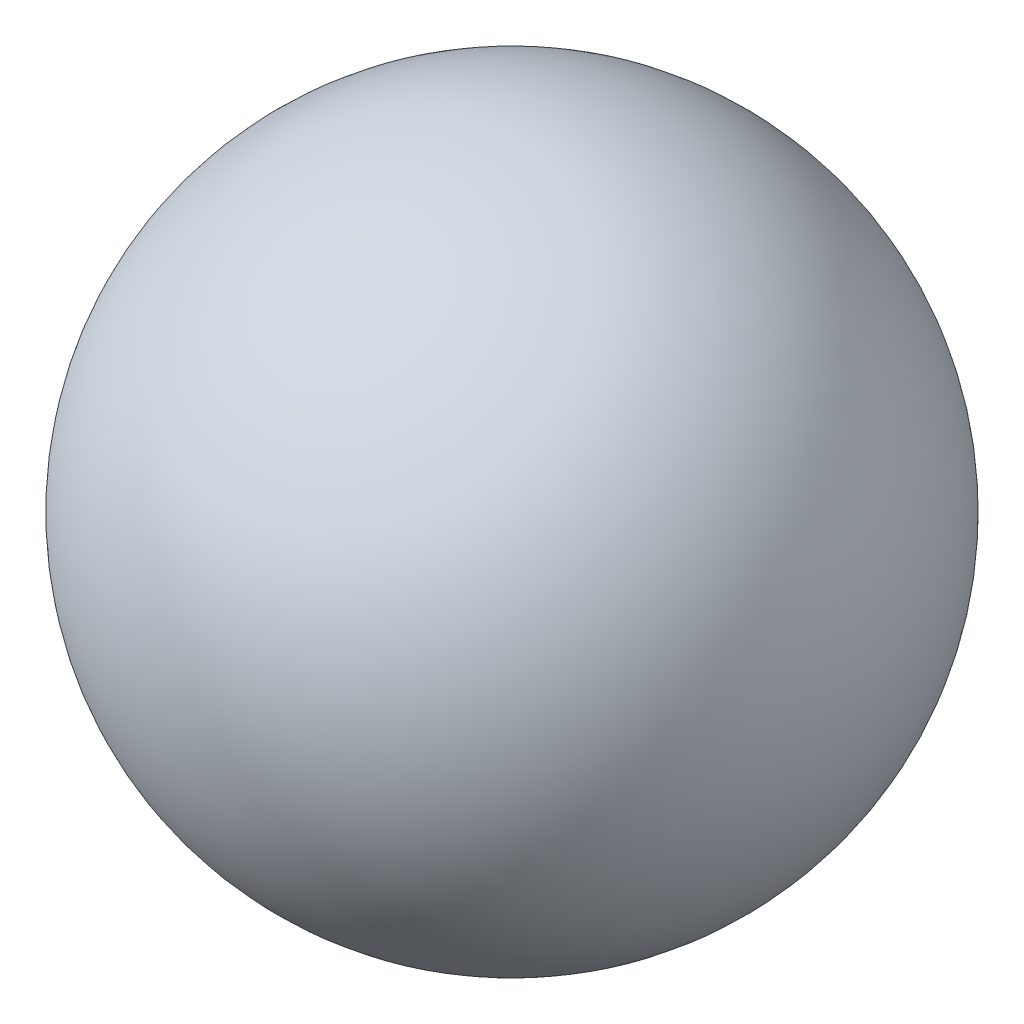
from build123d import *


with BuildPart() as part:
    # Sketch1 → Revolve2 (revolve)
    with BuildSketch(Plane.XY):
        with BuildLine():
            ThreePointArc((0, 165.1), (165.1, 0), (0, -165.1))
            Line((0, -165.1), (0, 165.1))
        make_face()
    revolve(axis=Axis((0, -165.1, 0), (0, 1, 0)))


solid = part.part
